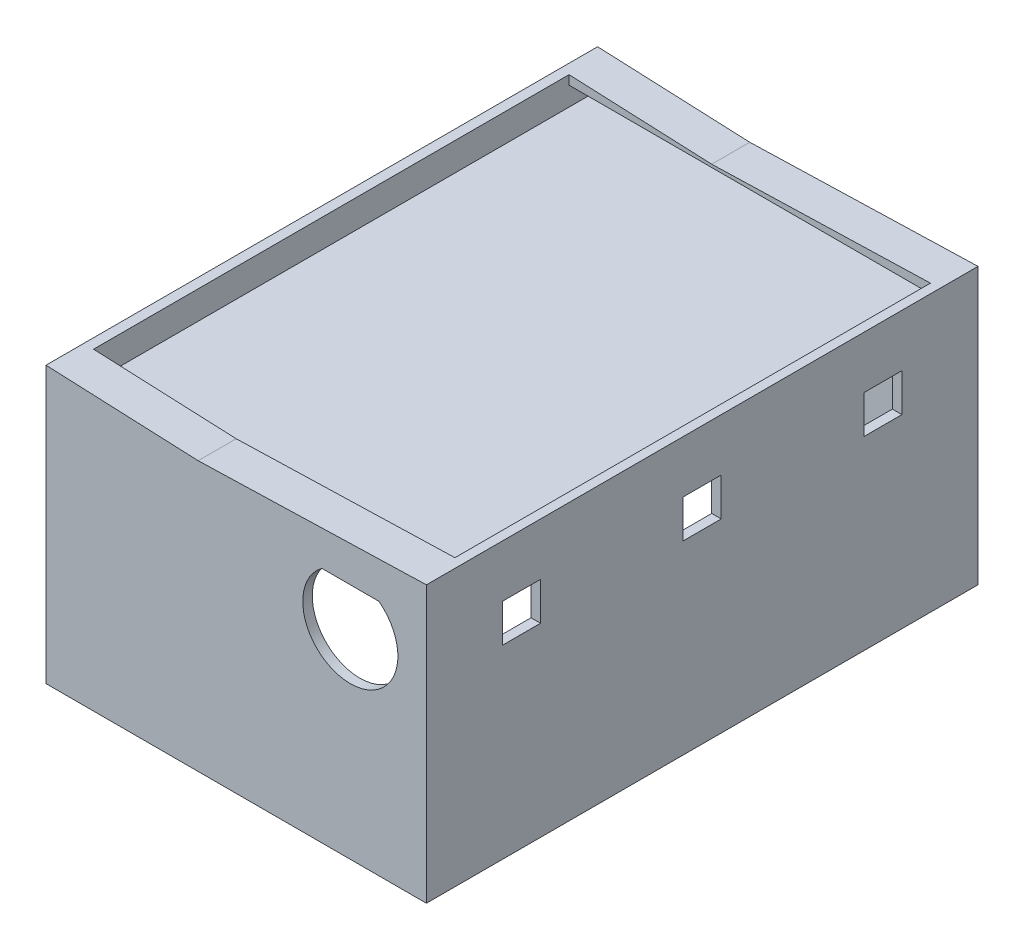
from build123d import *

# Parameters (mm, degrees)
SKETCH1_W            = 200
SKETCH1_H            = 290
BOSS_EXTRUDE2_DEPTH  = 10
BOSS_EXTRUDE4_DEPTH  = 140
SKETCH5_W            = 20
SKETCH5_H            = 20
CUT_EXTRUDE1_DEPTH   = 10
SKETCH6_R            = 3.78
CUT_EXTRUDE2_DEPTH   = 10
SKETCH7_R            = 25
CUT_EXTRUDE3_DEPTH   = 10
SKETCH8_W            = 190
SKETCH8_H            = 280
CUT_EXTRUDE4_DEPTH   = 10
SKETCH9_W            = 211.457715155
SKETCH9_H            = 301.376650104
CUT_EXTRUDE5_DEPTH   = 5
SKETCH10_W           = 200
SKETCH10_H           = 5
BOSS_EXTRUDE7_DEPTH  = 15
SKETCH12_W           = 200
SKETCH12_H           = 5
BOSS_EXTRUDE8_DEPTH  = 15
SKETCH13_W           = 290
SKETCH13_H           = 5
BOSS_EXTRUDE14_DEPTH = 190
CUT_EXTRUDE6_DEPTH   = 300


with BuildPart() as part:
    # Sketch1 → Boss-Extrude2 (new body)
    with BuildSketch(Plane(origin=(0, 0, 0), x_dir=(1, 0, 0), z_dir=(0, 1, 0))):
        with Locations((3.938356164, -87.893835616)):
            Rectangle(SKETCH1_W, SKETCH1_H)
    extrude(amount=BOSS_EXTRUDE2_DEPTH)

    # Sketch2 → Boss-Extrude4 (add)
    with BuildSketch(Plane(origin=(0, 10, 0), x_dir=(1, 0, 0), z_dir=(0, 1, 0))):
        Polygon((-96.061643836, 57.106164384), (-96.061643836, -87.893835616), (-91.061643836, -87.893835616), (-91.061643836, 52.106164384), (3.938356164, 52.106164384), (3.938356164, 57.106164384), align=None)
        Polygon((103.938356164, 57.106164384), (3.938356164, 57.106164384), (3.938356164, 52.106164384), (98.938356164, 52.106164384), (98.938356164, -87.893835616), (103.938356164, -87.893835616), align=None)
        Polygon((3.938356164, -227.893835616), (3.938356164, -232.893835616), (103.938356164, -232.893835616), (103.938356164, -87.893835616), (98.938356164, -87.893835616), (98.938356164, -227.893835616), align=None)
        Polygon((-91.061643836, -87.893835616), (-96.061643836, -87.893835616), (-96.061643836, -232.893835616), (3.938356164, -232.893835616), (3.938356164, -227.893835616), (-91.061643836, -227.893835616), align=None)
    extrude(amount=BOSS_EXTRUDE4_DEPTH)

    # Sketch5 → Cut-Extrude1 (cut)
    with BuildSketch(Plane(origin=(103.938356164, 0, 0), x_dir=(0, 0, -1), z_dir=(1, 0, 0))):
        with Locations((-182.893835616, 112.5)):
            Rectangle(SKETCH5_W, SKETCH5_H)
        with Locations((-87.893835616, 112.5)):
            Rectangle(SKETCH5_W, SKETCH5_H)
        with Locations((7.106164384, 112.5)):
            Rectangle(SKETCH5_W, SKETCH5_H)
    extrude(amount=-CUT_EXTRUDE1_DEPTH, mode=Mode.SUBTRACT)

    # Sketch6 → Cut-Extrude2 (cut)
    with BuildSketch(Plane.ZY.offset(96.061643836)):
        with Locations((185.476335616, 112.5)):
            Circle(SKETCH6_R)
        with Locations((-9.688664384, 112.5)):
            Circle(SKETCH6_R)
        with Locations((185.476335616, 61.57)):
            Circle(SKETCH6_R)
        with Locations((-9.688664384, 61.57)):
            Circle(SKETCH6_R)
    extrude(amount=-CUT_EXTRUDE2_DEPTH, mode=Mode.SUBTRACT)

    # Sketch7 → Cut-Extrude3 (cut)
    with BuildSketch(Plane.XY.offset(232.893835616)):
        with Locations((63.938356164, 110)):
            Circle(SKETCH7_R)
    extrude(amount=-CUT_EXTRUDE3_DEPTH, mode=Mode.SUBTRACT)

    # Sketch8 → Cut-Extrude4 (cut)
    with BuildSketch(Plane(origin=(0, 10, 0), x_dir=(1, 0, 0), z_dir=(0, 1, 0))):
        with Locations((3.938356164, -87.893835616)):
            Rectangle(SKETCH8_W, SKETCH8_H)
    extrude(amount=-CUT_EXTRUDE4_DEPTH, mode=Mode.SUBTRACT)

    # Sketch9 → Cut-Extrude5 (cut)
    with BuildSketch(Plane.XZ):
        with Locations((3.40694666, 89.005470801)):
            Rectangle(SKETCH9_W, SKETCH9_H)
    extrude(amount=-CUT_EXTRUDE5_DEPTH, mode=Mode.SUBTRACT)

    # Sketch10 → Boss-Extrude7 (add)
    with BuildSketch(Plane(origin=(0, 0, 227.893835616), x_dir=(-1, 0, 0), z_dir=(0, 0, -1))):
        with Locations((-3.938356164, 147.5)):
            Rectangle(SKETCH10_W, SKETCH10_H)
    extrude(amount=BOSS_EXTRUDE7_DEPTH)

    # Sketch12 → Boss-Extrude8 (add)
    with BuildSketch(Plane.XY.offset(-52.106164384)):
        with Locations((3.938356164, 147.5)):
            Rectangle(SKETCH12_W, SKETCH12_H)
    extrude(amount=BOSS_EXTRUDE8_DEPTH)

    # Sketch13 → Boss-Extrude14 (add)
    with BuildSketch(Plane(origin=(-91.061643836, 0, 0), x_dir=(0, 0, -1), z_dir=(1, 0, 0))):
        with Locations((-87.893835616, 132.5)):
            Rectangle(SKETCH13_W, SKETCH13_H)
    extrude(amount=BOSS_EXTRUDE14_DEPTH)

    # Sketch17 → Cut-Extrude6 (cut)
    with BuildSketch(Plane.XY.offset(232.893835616)):
        Polygon((-16.061643836, 150), (-96.061643836, 150), (-16.061643836, 146.51), align=None)
        Polygon((103.938356164, 150), (-16.061643836, 150), (-16.061643836, 146.51), align=None)
    extrude(amount=-CUT_EXTRUDE6_DEPTH, mode=Mode.SUBTRACT)


solid = part.part
